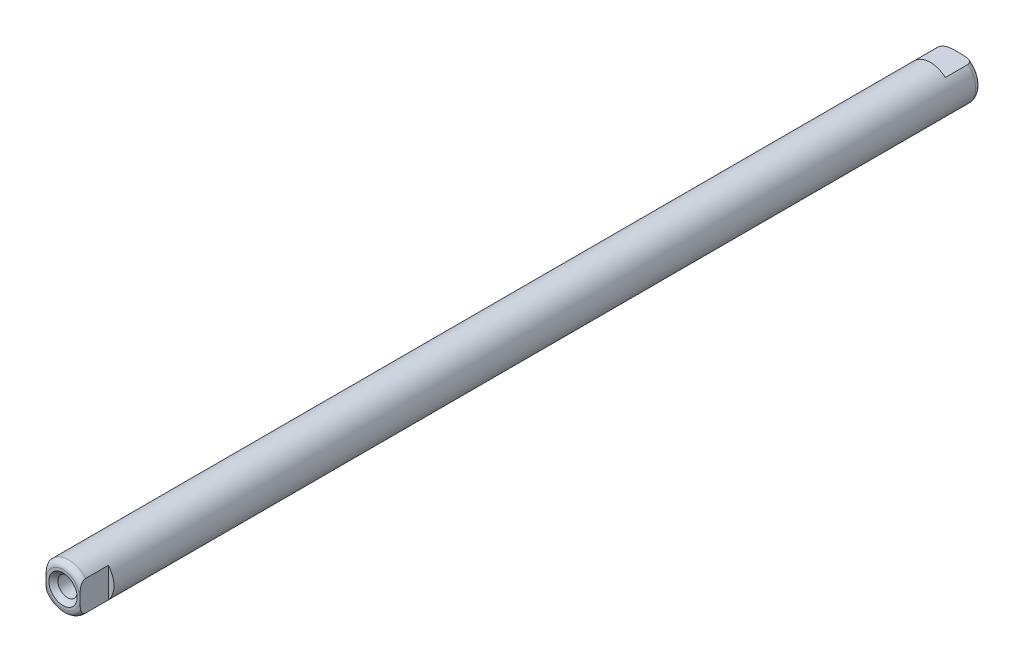
from build123d import *

# Parameters (mm, degrees)
ESQUISSE1_R             = 8
BOSS_EXTRU_1_DEPTH      = 158
CONG_1_R                = 2
ESQUISSE4_OUTSIDE_W     = 81.362
ESQUISSE4_OUTSIDE_H     = 81.362
ESQUISSE4_OUTSIDE_W_2   = 16
ESQUISSE4_OUTSIDE_H_2   = 12
ENL_V_MAT_EXTRU_1_DEPTH = 10
ESQUISSE5_OUTSIDE_W     = 81.362
ESQUISSE5_OUTSIDE_H     = 81.362
ESQUISSE5_OUTSIDE_W_2   = 12
ESQUISSE5_OUTSIDE_H_2   = 16
ENL_V_MAT_EXTRU_2_DEPTH = 10


with BuildPart() as part:
    # Esquisse1 → Boss.-Extru.1 (new body, symmetric)
    with BuildSketch(Plane.XY):
        Circle(ESQUISSE1_R)
    extrude(amount=BOSS_EXTRU_1_DEPTH, both=True)

    # Congé1
    cong_1_edges = [part.edges().sort_by_distance(p)[0] for p in [
        (-8, 0, -158),
        (-8, 0, 158),
    ]]
    fillet(cong_1_edges, radius=CONG_1_R)

    # Esquisse2 → Trou taraudé M81 (revolve, cut)
    with BuildSketch(Plane(origin=(0, 0, -158), x_dir=(0, 1, 0), z_dir=(1, 0, 0))):
        Polygon((0, 0), (0, 24.292926105), (3.4, 22.25), (3.4, 1.6), (5, 0), align=None)
    trou_taraud_m81 = revolve(axis=Axis((0, 0, -164.35), (0, 0, 1)), mode=Mode.SUBTRACT)

    # Symétrie5: Trou taraudé M81 across plane
    add(trou_taraud_m81.mirror(Plane.XY), mode=Mode.SUBTRACT)

    # Esquisse4 outside → Enlèv. mat.-Extru.1 (cut)
    with BuildSketch(Plane(origin=(0, 0, -158), x_dir=(-1, 0, 0), z_dir=(0, 0, -1))):
        Rectangle(ESQUISSE4_OUTSIDE_W, ESQUISSE4_OUTSIDE_H)
        Rectangle(ESQUISSE4_OUTSIDE_W_2, ESQUISSE4_OUTSIDE_H_2, mode=Mode.SUBTRACT)
    extrude(amount=-ENL_V_MAT_EXTRU_1_DEPTH, mode=Mode.SUBTRACT)

    # Esquisse5 outside → Enlèv. mat.-Extru.2 (cut)
    with BuildSketch(Plane.XY.offset(158)):
        Rectangle(ESQUISSE5_OUTSIDE_W, ESQUISSE5_OUTSIDE_H)
        Rectangle(ESQUISSE5_OUTSIDE_W_2, ESQUISSE5_OUTSIDE_H_2, mode=Mode.SUBTRACT)
    extrude(amount=-ENL_V_MAT_EXTRU_2_DEPTH, mode=Mode.SUBTRACT)


solid = part.part
